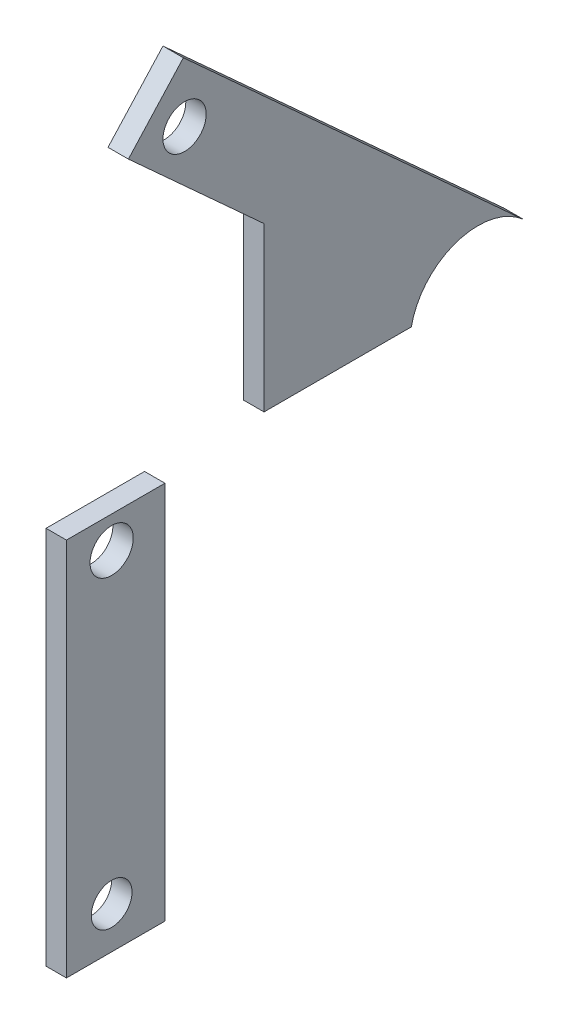
from build123d import *

# Parameters (mm, degrees)
CROQUIS1_R                = 5.3
SALIENTE_EXTRUIR1_DEPTH   = 5
CROQUIS1_W                = 24.144167284
CROQUIS1_H                = 92.987671296
CROQUIS1_R_2              = 5
SALIENTE_EXTRUIR1_2_DEPTH = 5


with BuildPart() as part:
    # Croquis1 → Saliente-Extruir1 (new body)
    with BuildSketch(Plane(origin=(0, 0, 0), x_dir=(0, 0, -1), z_dir=(1, 0, 0))):
        with BuildLine():
            Line((73.557707563, 13.873274173), (-9.950288611, 90.000894489))
            Line((-9.950288611, 90.000894489), (-23.424203712, 75.220718175))
            Line((-23.424203712, 75.220718175), (9.831192995, 44.9044092))
            Line((9.831192995, 44.9044092), (9.831192995, 4.9044092))
            Line((9.831192995, 4.9044092), (45.950310428, 4.9044092))
            ThreePointArc((45.950310428, 4.9044092), (57.146601313, 17.414800332), (73.557707563, 13.873274173))
        make_face()
        with Locations((-9.651058952, 75.240303355)):
            Circle(CROQUIS1_R, mode=Mode.SUBTRACT)
    extrude(amount=SALIENTE_EXTRUIR1_DEPTH)


with BuildPart() as body_2:
    # Croquis1 → Saliente-Extruir1 2 (new body)
    with BuildSketch(Plane(origin=(0, 0, 0), x_dir=(0, 0, -1), z_dir=(1, 0, 0))):
        with Locations((-26.539381131, -44.567693736)):
            Rectangle(CROQUIS1_W, CROQUIS1_H)
        with Locations((-27.531274421, -5.827010277)):
            Circle(CROQUIS1_R, mode=Mode.SUBTRACT)
        with Locations((-27.531274421, -80.852812864)):
            Circle(CROQUIS1_R_2, mode=Mode.SUBTRACT)
    extrude(amount=SALIENTE_EXTRUIR1_2_DEPTH)


solid = Compound([part.part, body_2.part])
